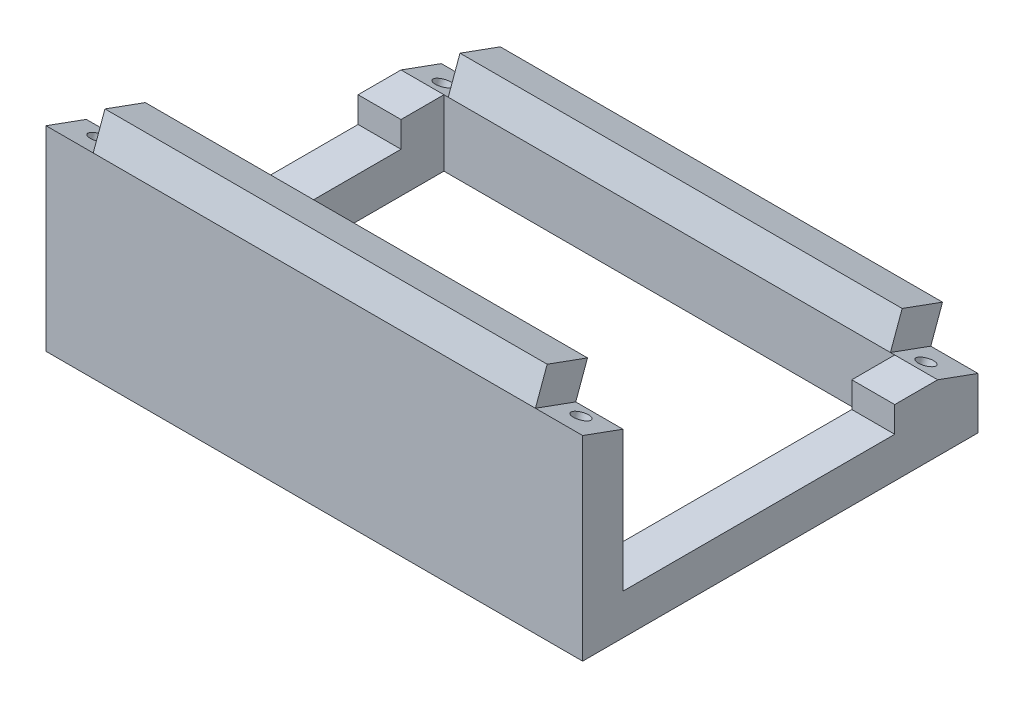
from build123d import *

# Parameters (mm, degrees)
BOSS_EXTRUDE3_DEPTH  = 125
SKETCH3_W            = 125
SKETCH3_H            = 92.089876837
BOSS_EXTRUDE5_DEPTH  = 12
CUT_EXTRUDE1_DEPTH   = 126
SKETCH7_W            = 105
SKETCH7_H            = 10
BOSS_EXTRUDE6_DEPTH  = 8
SKETCH8_W            = 105
SKETCH8_H            = 10
BOSS_EXTRUDE7_DEPTH  = 8
SKETCH9_W            = 105
SKETCH9_H            = 73.296024421
CUT_EXTRUDE2_DEPTH   = 16.420201433
SKETCH11_W           = 10
SKETCH11_H           = 73.296024421
CUT_EXTRUDE3_DEPTH   = 6
SKETCH12_W           = 10
SKETCH12_H           = 73.296024421
CUT_EXTRUDE4_DEPTH   = 6
SKETCH13_W           = 105
SKETCH13_H           = 32.67757118
CUT_EXTRUDE6_DEPTH   = 3
SKETCH14_R           = 1.9
CUT_EXTRUDE8_DEPTH   = 6
SKETCH15_R           = 1.9
CUT_EXTRUDE9_DEPTH   = 6
BOSS_EXTRUDE9_REACH  = 117
SKETCH25_W           = 10
SKETCH25_H           = 6
BOSS_EXTRUDE13_DEPTH = 10
CUT_EXTRUDE10_DEPTH  = 1
CUT_EXTRUDE11_DEPTH  = 1


with BuildPart() as part:
    # Sketch1 → Boss-Extrude3 (new body)
    with BuildSketch(Plane(origin=(0, 0, 0), x_dir=(0, 0, -1), z_dir=(1, 0, 0))):
        Polygon((0, 0), (92.089876837, 0), (0, 33.517974046), align=None)
    extrude(amount=-BOSS_EXTRUDE3_DEPTH)

    # Sketch3 → Boss-Extrude5 (add)
    with BuildSketch(Plane.XZ):
        with Locations((-62.5, -46.044938419)):
            Rectangle(SKETCH3_W, SKETCH3_H)
    extrude(amount=BOSS_EXTRUDE5_DEPTH)

    # Sketch6 → Cut-Extrude1 (cut, through all)
    with BuildSketch(Plane.ZY.offset(125)):
        Polygon((-9.396926208, 30.097772613), (-82.692950629, 3.420201433), (-9.396926208, 3.420201433), align=None)
    extrude(amount=-CUT_EXTRUDE1_DEPTH, mode=Mode.SUBTRACT)

    # Sketch7 → Boss-Extrude6 (add)
    with BuildSketch(Plane(origin=(0, 29.597115904, -10.772469209), x_dir=(1, 0, 0), z_dir=(0, 0.939692621, -0.342020143))):
        with Locations((-62.5, 81.536177713)):
            Rectangle(SKETCH7_W, SKETCH7_H)
    extrude(amount=BOSS_EXTRUDE6_DEPTH)

    # Sketch8 → Boss-Extrude7 (add)
    with BuildSketch(Plane(origin=(0, 29.597115904, -10.772469209), x_dir=(1, 0, 0), z_dir=(0, 0.939692621, -0.342020143))):
        with Locations((-62.5, -6.463822287)):
            Rectangle(SKETCH8_W, SKETCH8_H)
    extrude(amount=BOSS_EXTRUDE7_DEPTH)

    # Sketch9 → Cut-Extrude2 (cut, through all)
    with BuildSketch(Plane(origin=(0, 3.420201433, 0), x_dir=(1, 0, 0), z_dir=(0, 1, 0))):
        with Locations((-62.5, 46.044938419)):
            Rectangle(SKETCH9_W, SKETCH9_H)
    extrude(amount=-CUT_EXTRUDE2_DEPTH, mode=Mode.SUBTRACT)

    # Sketch11 → Cut-Extrude3 (cut)
    with BuildSketch(Plane(origin=(0, 3.420201433, 0), x_dir=(1, 0, 0), z_dir=(0, 1, 0))):
        with Locations((-5, 46.044938419)):
            Rectangle(SKETCH11_W, SKETCH11_H)
    extrude(amount=-CUT_EXTRUDE3_DEPTH, mode=Mode.SUBTRACT)

    # Sketch12 → Cut-Extrude4 (cut)
    with BuildSketch(Plane(origin=(0, 3.420201433, 0), x_dir=(1, 0, 0), z_dir=(0, 1, 0))):
        with Locations((-120, 46.044938419)):
            Rectangle(SKETCH12_W, SKETCH12_H)
    extrude(amount=-CUT_EXTRUDE4_DEPTH, mode=Mode.SUBTRACT)

    # Sketch13 → Cut-Extrude6 (cut)
    with BuildSketch(Plane(origin=(0, 0, -9.396926208), x_dir=(-1, 0, 0), z_dir=(0, 0, -1))):
        with Locations((62.5, 13.758987023)):
            Rectangle(SKETCH13_W, SKETCH13_H)
    extrude(amount=-CUT_EXTRUDE6_DEPTH, mode=Mode.SUBTRACT)

    # Sketch14 → Cut-Extrude8 (cut)
    with BuildSketch(Plane(origin=(0, 29.597115904, -10.772469209), x_dir=(1, 0, 0), z_dir=(0, 0.939692621, -0.342020143))):
        with Locations((-6.25, 80.286177713)):
            Circle(SKETCH14_R)
    cut_extrude8 = extrude(amount=-CUT_EXTRUDE8_DEPTH, mode=Mode.SUBTRACT)

    # Mirror1: Cut-Extrude8 across plane
    add(cut_extrude8.mirror(Plane(origin=(-62.5, 0, 0), x_dir=(0, 0, 1), z_dir=(1, 0, 0))), mode=Mode.SUBTRACT)

    # Sketch15 → Cut-Extrude9 (cut)
    with BuildSketch(Plane(origin=(0, 29.597115904, -10.772469209), x_dir=(1, 0, 0), z_dir=(0, 0.939692621, -0.342020143))):
        with Locations((-6.25, -5.213822287)):
            Circle(SKETCH15_R)
    cut_extrude9 = extrude(amount=-CUT_EXTRUDE9_DEPTH, mode=Mode.SUBTRACT)

    # Mirror2: Cut-Extrude9 across plane
    add(cut_extrude9.mirror(Plane(origin=(-62.5, 0, 0), x_dir=(0, 0, 1), z_dir=(1, 0, 0))), mode=Mode.SUBTRACT)

    # Sketch22 → Boss-Extrude9 (add, up to next)
    with BuildSketch(Plane.ZY.offset(10), mode=Mode.PRIVATE) as boss_extrude9_sk1:
        Polygon((-9.396926208, 30.097772613), (-6.396926208, 21.855340354), (-6.396926208, 30.097772613), align=None)
    boss_extrude9_tool1 = extrude(boss_extrude9_sk1.sketch, amount=BOSS_EXTRUDE9_REACH, mode=Mode.PRIVATE) - part.part
    add(boss_extrude9_tool1.solids().sort_by_distance((-10, 27.350295, -7.396926))[0])

    # Sketch25 → Boss-Extrude13 (add)
    with BuildSketch(Plane.XY.offset(-82.692950629)):
        with Locations((-5, 0.420201433)):
            Rectangle(SKETCH25_W, SKETCH25_H)
        with Locations((-120, 0.420201433)):
            Rectangle(SKETCH25_W, SKETCH25_H)
    extrude(amount=BOSS_EXTRUDE13_DEPTH)

    # Sketch26 → Cut-Extrude10 (cut)
    with BuildSketch(Plane(origin=(-10, 0, 0), x_dir=(0, 0, -1), z_dir=(1, 0, 0))):
        Polygon((0, 33.517974046), (9.396926208, 30.097772613), (12.133087354, 37.615313579), (2.736161147, 41.035515012), align=None)
    cut_extrude10 = extrude(amount=-CUT_EXTRUDE10_DEPTH, mode=Mode.SUBTRACT)

    # Sketch27 → Cut-Extrude11 (cut)
    with BuildSketch(Plane(origin=(-10, 0, 0), x_dir=(0, 0, -1), z_dir=(1, 0, 0))):
        Polygon((82.692950629, 3.420201433), (92.089876837, 0), (94.826037984, 7.517540966), (85.429111776, 10.9377424), align=None)
    cut_extrude11 = extrude(amount=-CUT_EXTRUDE11_DEPTH, mode=Mode.SUBTRACT)

    # Mirror3: Cut-Extrude10, Cut-Extrude11 across plane
    add(cut_extrude10.mirror(Plane(origin=(-62.5, 0, 0), x_dir=(0, 0, 1), z_dir=(1, 0, 0))), mode=Mode.SUBTRACT)
    add(cut_extrude11.mirror(Plane(origin=(-62.5, 0, 0), x_dir=(0, 0, 1), z_dir=(1, 0, 0))), mode=Mode.SUBTRACT)


solid = part.part
